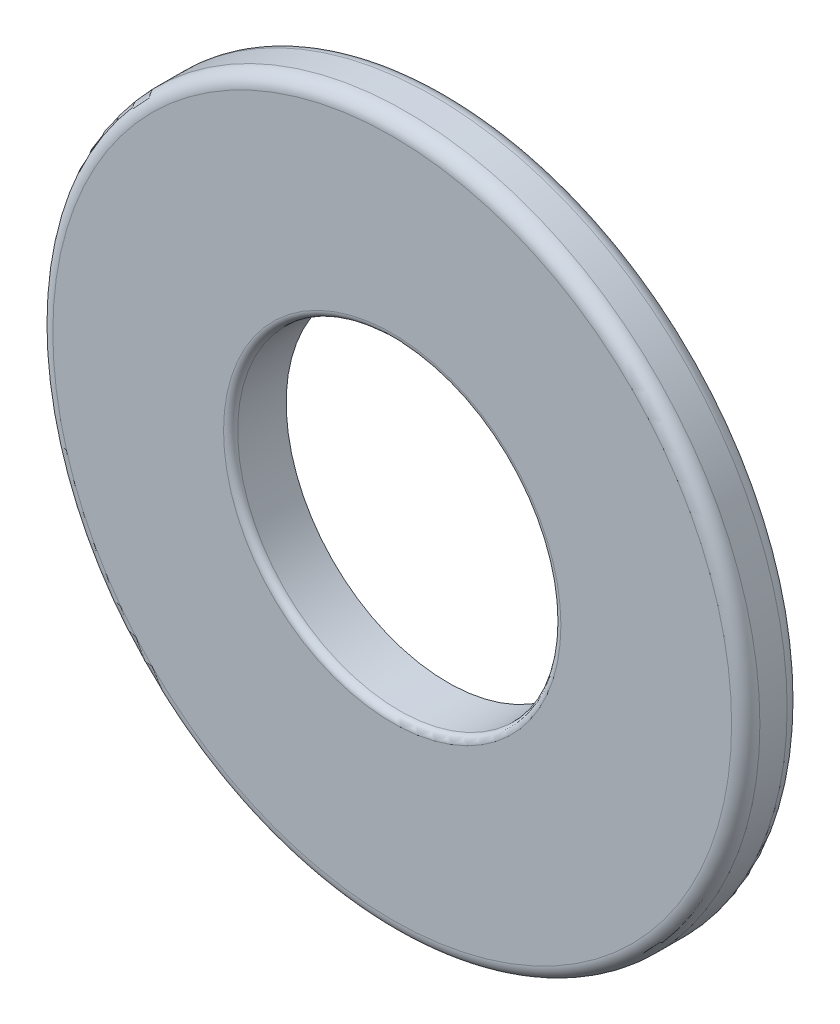
from build123d import *

# Parameters (mm, degrees)
SKETCH3_R                = 3.5
SKETCH3_R_2              = 1.6
BOSS_EXTRUDE1_DEPTH      = 0.275
BOSS_EXTRUDE1_DEPTH_BACK = 0.275
FILLET1_R                = 0.14
FILLET2_R                = 0.07


with BuildPart() as part:
    # Sketch3 → Boss-Extrude1 (new body, two sides)
    with BuildSketch(Plane.XY) as boss_extrude1_sk:
        Circle(SKETCH3_R)
        Circle(SKETCH3_R_2, mode=Mode.SUBTRACT)
    extrude(amount=BOSS_EXTRUDE1_DEPTH)
    extrude(boss_extrude1_sk.sketch, amount=-BOSS_EXTRUDE1_DEPTH_BACK)

    # Fillet1
    fillet1_edges = [part.edges().sort_by_distance(p)[0] for p in [
        (-3.5, 0, -0.275),
        (-3.5, 0, 0.275),
    ]]
    fillet(fillet1_edges, radius=FILLET1_R)

    # Fillet2
    fillet2_edges = [part.edges().sort_by_distance(p)[0] for p in [
        (-1.6, 0, 0.275),
    ]]
    fillet(fillet2_edges, radius=FILLET2_R)


solid = part.part
